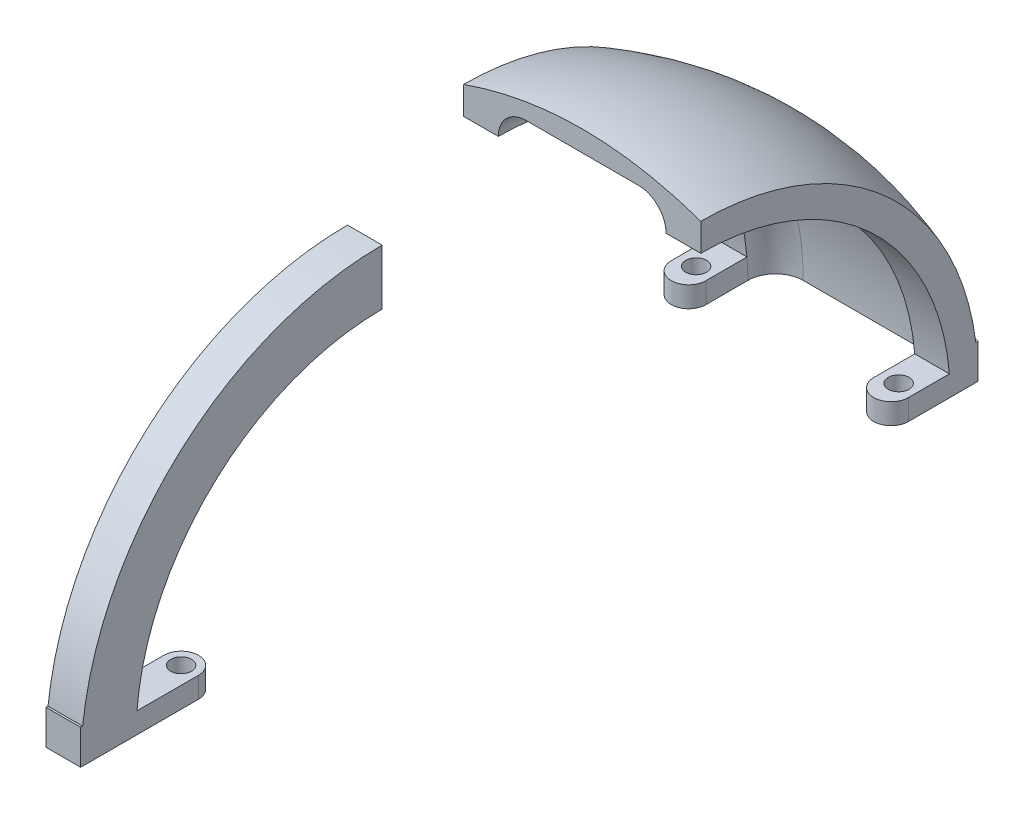
from build123d import *

# Parameters (mm, degrees)
SKETCH1_R             = 1.5
BOSS_EXTRUDE1_DEPTH   = 3
BOSS_EXTRUDE1_2_DEPTH = 3
SKETCH1_4_W           = 5
SKETCH1_4_H           = 8
BOSS_EXTRUDE2_DEPTH   = 5
REVOLVE3_ANGLE        = 90
SKETCH1_6_W           = 5
SKETCH1_6_H           = 8
REVOLVE5_ANGLE        = 90


with BuildPart() as part:
    # Sketch1 → Boss-Extrude1 (new body)
    with BuildSketch(Plane(origin=(0, 0, 0), x_dir=(1, 0, 0), z_dir=(0, 1, 0))):
        with BuildLine():
            ThreePointArc((-10.2, 50.045906413), (-9.028427125, 52.874333538), (-6.2, 54.045906413))
            Line((-6.2, 54.045906413), (10.01, 54.045906413))
            ThreePointArc((10.01, 54.045906413), (12.838427125, 52.874333538), (14.01, 50.045906413))
            Line((14.01, 50.045906413), (14.01, 44))
            ThreePointArc((14.01, 44), (16.51, 41.5), (19.01, 44))
            Line((19.01, 44), (19.01, 54.045906413))
            add(Edge.make_bspline(
                [(-15.2, 54.045906413), (1.905, 60.045906413), (19.01, 54.045906413)],
                knots=[0, 0, 0, 1, 1, 1], degree=2))
            Line((-15.2, 54.045906413), (-15.2, 44))
            ThreePointArc((-15.2, 44), (-12.7, 41.5), (-10.2, 44))
            Line((-10.2, 44), (-10.2, 50.045906413))
        make_face()
        with Locations((-12.704913633, 45.091234874)):
            Circle(SKETCH1_R, mode=Mode.SUBTRACT)
        with Locations((16.532679199, 45.078375192)):
            Circle(SKETCH1_R, mode=Mode.SUBTRACT)
    extrude(amount=BOSS_EXTRUDE1_DEPTH)



with BuildPart() as body_2:
    # Sketch1 → Boss-Extrude1 2 (new body)
    with BuildSketch(Plane(origin=(0, 0, 0), x_dir=(1, 0, 0), z_dir=(0, 1, 0))):
        with BuildLine():
            ThreePointArc((2.5, -41.91), (0, -39.41), (-2.5, -41.91))
            Line((-2.5, -41.91), (-2.5, -58.91))
            Line((-2.5, -58.91), (2.5, -58.91))
            Line((2.5, -58.91), (2.5, -41.91))
        make_face()
        with Locations((0, -41.91)):
            Circle(SKETCH1_R, mode=Mode.SUBTRACT)
    extrude(amount=BOSS_EXTRUDE1_2_DEPTH)


with BuildPart() as part_1:
    add(part.part)

    add(body_2.part)  # Boss-Extrude2 merges body 2
    # Sketch1_4 → Boss-Extrude2 (add)
    with BuildSketch(Plane(origin=(0, 0, 0), x_dir=(1, 0, 0), z_dir=(0, 1, 0))):
        with BuildLine():
            ThreePointArc((-10.2, 50.045906413), (-9.028427125, 52.874333538), (-6.2, 54.045906413))
            Line((-6.2, 54.045906413), (10.01, 54.045906413))
            ThreePointArc((10.01, 54.045906413), (12.838427125, 52.874333538), (14.01, 50.045906413))
            Line((14.01, 50.045906413), (19.01, 50.045906413))
            Line((19.01, 50.045906413), (19.01, 54.045906413))
            add(Edge.make_bspline(
                [(-15.2, 54.045906413), (1.905, 60.045906413), (19.01, 54.045906413)],
                knots=[0, 0, 0, 1, 1, 1], degree=2))
            Line((-15.2, 54.045906413), (-15.2, 50.045906413))
            Line((-15.2, 50.045906413), (-10.2, 50.045906413))
        make_face()
        with Locations((0, -54.91)):
            Rectangle(SKETCH1_4_W, SKETCH1_4_H)
    extrude(amount=BOSS_EXTRUDE2_DEPTH)

    # Sketch6 → Revolve3 (revolve)
    with BuildSketch(Plane.XZ):
        with BuildLine():
            Line((-10.2, -50.045906413), (-15.2, -50.045906413))
            Line((-15.2, -50.045906413), (-15.2, -54.045906413))
            add(Edge.make_bspline(
                [(-15.2, -54.045906413), (1.905000001, -60.045906413), (19.010000002, -54.045906412)],
                knots=[0, 0, 0, 1, 1, 1], degree=2))
            Line((19.010000002, -54.045906412), (19.010000001, -50.045906413))
            Line((19.01, -50.045906413), (14.01, -50.045906413))
            ThreePointArc((14.01, -50.045906413), (12.838427125, -52.874333538), (10.01, -54.045906413))
            Line((10.01, -54.045906413), (-6.2, -54.045906413))
            ThreePointArc((-6.2, -54.045906413), (-9.028427125, -52.874333538), (-10.2, -50.045906413))
        make_face()
    revolve(axis=Axis((-6.2, 0, -14.045906413), (1, 0, 0)), revolution_arc=REVOLVE3_ANGLE)

    # Sketch1_6 → Revolve5 (revolve)
    with BuildSketch(Plane(origin=(0, 0, 0), x_dir=(1, 0, 0), z_dir=(0, 1, 0))):
        with Locations((0, -54.91)):
            Rectangle(SKETCH1_6_W, SKETCH1_6_H)
    revolve(axis=Axis((-2.5, 0, 15.41), (-1, 0, 0)), revolution_arc=REVOLVE5_ANGLE)


solid = part_1.part
